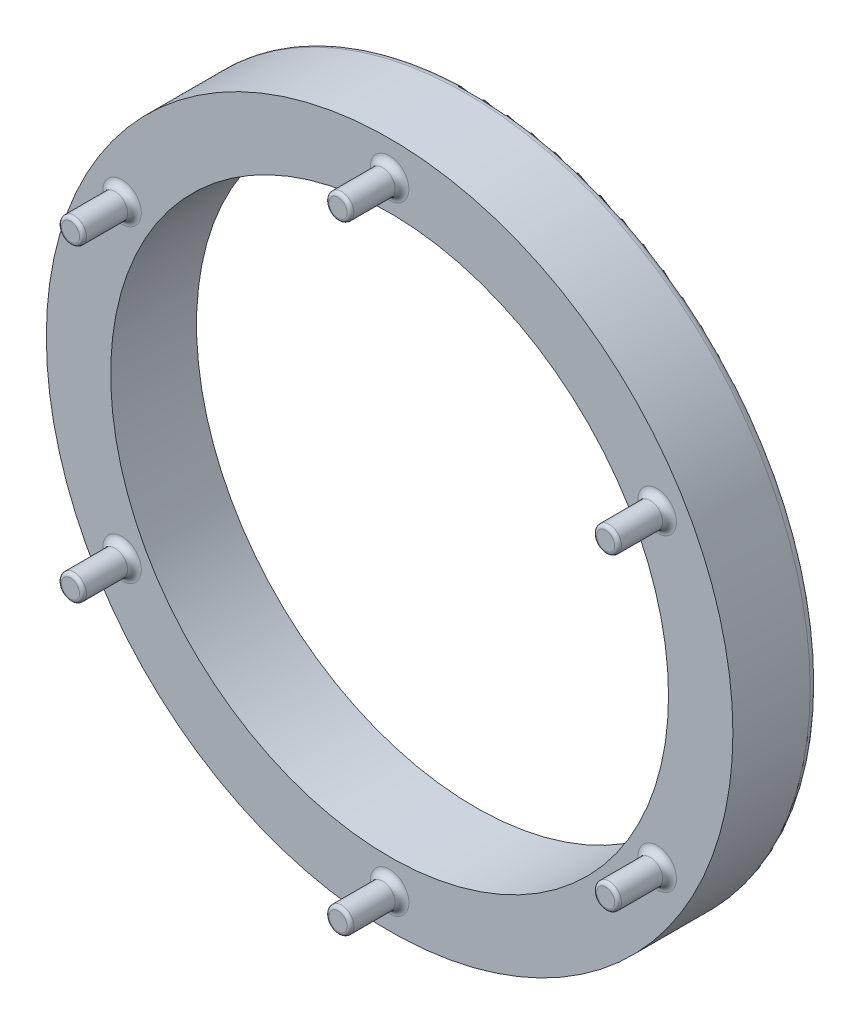
from build123d import *

# Parameters (mm, degrees)
SKETCH1_R               = 20
BOSS_EXTRUDE1_DEPTH     = 5
SKETCH3_R               = 0.725
BOSS_EXTRUDE3_DEPTH     = 3
FILLET1_R               = 0.4
SKETCH4_R               = 8.5
CUT_EXTRUDE2_DEPTH      = 1.5
SKETCH6_R               = 5
BOSS_EXTRUDE4_DEPTH     = 0.5
SKETCH7_R               = 4
BOSS_EXTRUDE6_DEPTH     = 4.5
FILLET2_R               = 0.5
FILLET3_R               = 0.5
FILLET4_R               = 0.5
FILLET5_R               = 0.2
SKETCH8_R               = 16.25
CUT_EXTRUDE4_DEPTH      = 1
FILLET6_R               = 0.2
SKETCH9_R               = 16.25
CUT_EXTRUDE5_DEPTH      = 5
CUT_EXTRUDE5_DEPTH_BACK = 8.5


with BuildPart() as part:
    # Sketch1 → Boss-Extrude1 (new body)
    with BuildSketch(Plane.XY):
        Circle(SKETCH1_R)
    extrude(amount=BOSS_EXTRUDE1_DEPTH)

    # Sketch3 → Boss-Extrude3 (add)
    with BuildSketch(Plane.XY.offset(5)):
        with Locations((0, 18)):
            Circle(SKETCH3_R)
        with Locations((15.588457268, 9)):
            Circle(SKETCH3_R)
        with Locations((15.588457268, -9)):
            Circle(SKETCH3_R)
        with Locations((0, -18)):
            Circle(SKETCH3_R)
        with Locations((-15.588457268, -9)):
            Circle(SKETCH3_R)
        with Locations((-15.588457268, 9)):
            Circle(SKETCH3_R)
    extrude(amount=BOSS_EXTRUDE3_DEPTH)

    # Fillet1
    fillet1_edges = [part.edges().sort_by_distance(p)[0] for p in [
        (14.863457268, -9, 5),
        (-0.725, -18, 5),
        (-16.313457268, -9, 5),
        (-16.313457268, 9, 5),
        (-0.725, 18, 5),
        (14.863457268, 9, 5),
    ]]
    fillet(fillet1_edges, radius=FILLET1_R)

    # Sketch4 → Cut-Extrude2 (cut)
    with BuildSketch(Plane(origin=(0, 0, 0), x_dir=(-1, 0, 0), z_dir=(0, 0, -1))):
        Circle(SKETCH4_R)
    extrude(amount=-CUT_EXTRUDE2_DEPTH, mode=Mode.SUBTRACT)

    # Sketch6 → Boss-Extrude4 (add)
    with BuildSketch(Plane(origin=(0, 0, 1.5), x_dir=(-1, 0, 0), z_dir=(0, 0, -1))):
        Circle(SKETCH6_R)
    extrude(amount=BOSS_EXTRUDE4_DEPTH)

    # Sketch7 → Boss-Extrude6 (add)
    with BuildSketch(Plane(origin=(0, 0, 1), x_dir=(-1, 0, 0), z_dir=(0, 0, -1))):
        Circle(SKETCH7_R)
    extrude(amount=BOSS_EXTRUDE6_DEPTH)

    # Fillet2
    fillet2_edges = [part.edges().sort_by_distance(p)[0] for p in [
        (-20, 0, 0),
    ]]
    fillet(fillet2_edges, radius=FILLET2_R)

    # Fillet3
    fillet3_edges = [part.edges().sort_by_distance(p)[0] for p in [
        (8.5, 0, 0),
    ]]
    fillet(fillet3_edges, radius=FILLET3_R)

    # Fillet4
    fillet4_edges = [part.edges().sort_by_distance(p)[0] for p in [
        (4, 0, -3.5),
    ]]
    fillet(fillet4_edges, radius=FILLET4_R)

    # Fillet5
    fillet5_edges = [part.edges().sort_by_distance(p)[0] for p in [
        (14.863457268, -9, 8),
        (-0.725, -18, 8),
        (-16.313457268, -9, 8),
        (-16.313457268, 9, 8),
        (-0.725, 18, 8),
        (14.863457268, 9, 8),
    ]]
    fillet(fillet5_edges, radius=FILLET5_R)

    # Sketch8 → Cut-Extrude4 (cut)
    with BuildSketch(Plane.XY.offset(5)):
        Circle(SKETCH8_R)
    extrude(amount=-CUT_EXTRUDE4_DEPTH, mode=Mode.SUBTRACT)

    # Fillet6
    fillet6_edges = [part.edges().sort_by_distance(p)[0] for p in [
        (-16.25, 0, 4),
    ]]
    fillet(fillet6_edges, radius=FILLET6_R)

    # Sketch9 → Cut-Extrude5 (cut, two sides)
    with BuildSketch(Plane.XY.offset(4)) as cut_extrude5_sk:
        Circle(SKETCH9_R)
    extrude(amount=CUT_EXTRUDE5_DEPTH, mode=Mode.SUBTRACT)
    extrude(cut_extrude5_sk.sketch, amount=-CUT_EXTRUDE5_DEPTH_BACK, mode=Mode.SUBTRACT)


solid = part.part
